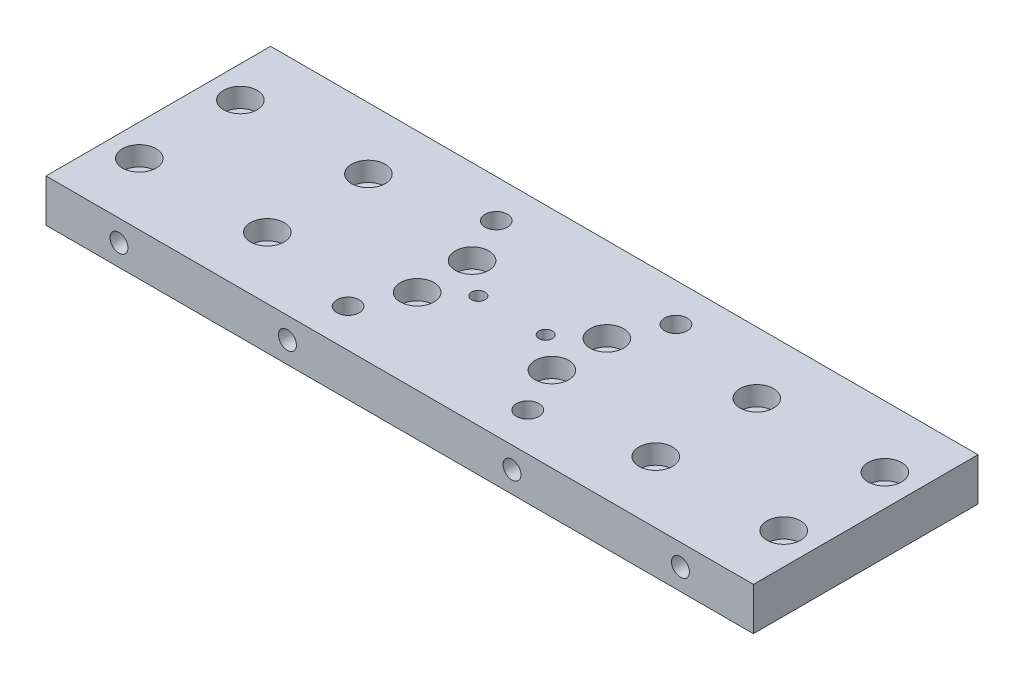
from build123d import *

# Parameters (mm, degrees)
ESBO_O1_W                                            = 315
ESBO_O1_H                                            = 100
RESSALTO_EXTRUS_O1_DEPTH                             = 19.02
ESBO_O2_R                                            = 2
CORTE_EXTRUS_O1_DEPTH                                = 25
ESBO_O4_R                                            = 5
CORTE_EXTRUS_O3_DEPTH                                = 20.02
ESBO_O5_R                                            = 3.3
CORTE_EXTRUS_O4_DEPTH                                = 90
REBAIXO_PARA_PARAFUSO_ALLEN_SEXTAVADO_DE_D           = 9
REBAIXO_PARA_PARAFUSO_ALLEN_SEXTAVADO_DE_DEPTH       = 19.02
REBAIXO_PARA_PARAFUSO_ALLEN_SEXTAVADO_DE_CBORE_D     = 15
REBAIXO_PARA_PARAFUSO_ALLEN_SEXTAVADO_DE_CBORE_DEPTH = 8.6
ESBO_O13_R                                           = 4
CORTE_EXTRUS_O8_DEPTH                                = 20
ESBO_O14_R                                           = 4
CORTE_EXTRUS_O9_DEPTH                                = 20
ESBO_O15_R                                           = 4
ESBO_O15_R_2                                         = 3
CORTE_EXTRUS_O10_DEPTH                               = 20.02
ESBO_O16_R                                           = 3.3
RESSALTO_EXTRUS_O2_DEPTH                             = 19.02
REBAIXO_PARA_PARAFUSO_ALLEN_SEXTAVAD_2_D             = 9
REBAIXO_PARA_PARAFUSO_ALLEN_SEXTAVAD_2_CBORE_D       = 15
REBAIXO_PARA_PARAFUSO_ALLEN_SEXTAVAD_2_CBORE_DEPTH   = 8.6


with BuildPart() as part:
    # Esboço1 → Ressalto-extrusão1 (new body)
    with BuildSketch(Plane(origin=(0, 0, 0), x_dir=(1, 0, 0), z_dir=(0, 1, 0))):
        Rectangle(ESBO_O1_W, ESBO_O1_H)
    extrude(amount=RESSALTO_EXTRUS_O1_DEPTH)

    # Esboço2 → Corte-extrusão1 (cut)
    with BuildSketch(Plane(origin=(0, 19.02, 0), x_dir=(1, 0, 0), z_dir=(0, 1, 0))):
        with Locations((143.5, 22.5)):
            Circle(ESBO_O2_R)
        with Locations((86.5, 22.5)):
            Circle(ESBO_O2_R)
        with Locations((86.5, -22.5)):
            Circle(ESBO_O2_R)
        with Locations((143.5, -22.5)):
            Circle(ESBO_O2_R)
        with Locations((-86.5, -22.45)):
            Circle(ESBO_O2_R)
        with Locations((-143.5, -22.45)):
            Circle(ESBO_O2_R)
        with Locations((-143.5, 22.55)):
            Circle(ESBO_O2_R)
        with Locations((-86.5, 22.55)):
            Circle(ESBO_O2_R)
    extrude(amount=-CORTE_EXTRUS_O1_DEPTH, mode=Mode.SUBTRACT)

    # Esboço4 → Corte-extrusão3 (cut, through all)
    with BuildSketch(Plane(origin=(0, 19.02, 0), x_dir=(1, 0, 0), z_dir=(0, 1, 0))):
        with Locations((-40, -32.999878702)):
            Circle(ESBO_O4_R)
        with Locations((-40, 33)):
            Circle(ESBO_O4_R)
        with Locations((40, 33)):
            Circle(ESBO_O4_R)
        with Locations((40, -33)):
            Circle(ESBO_O4_R)
    extrude(amount=-CORTE_EXTRUS_O3_DEPTH, mode=Mode.SUBTRACT)

    # Esboço5 → Corte-extrusão4 (cut)
    with BuildSketch(Plane(origin=(0, 19.02, 0), x_dir=(1, 0, 0), z_dir=(0, 1, 0))):
        Circle(ESBO_O5_R)
    extrude(amount=-CORTE_EXTRUS_O4_DEPTH, mode=Mode.SUBTRACT)

    # Rebaixo para parafuso Allen sextavado de
    with Locations(Plane(origin=(-143.5, 19.02, -22.55), x_dir=(0, 0, 1), z_dir=(0, 1, 0))):
        with Locations((0, 0), (45, 57), (0, 57), (45, 0), (0.05, 230), (0.05, 287), (45.05, 230), (45.05, 287)):
            CounterBoreHole(REBAIXO_PARA_PARAFUSO_ALLEN_SEXTAVADO_DE_D / 2, REBAIXO_PARA_PARAFUSO_ALLEN_SEXTAVADO_DE_CBORE_D / 2, REBAIXO_PARA_PARAFUSO_ALLEN_SEXTAVADO_DE_CBORE_DEPTH, depth=REBAIXO_PARA_PARAFUSO_ALLEN_SEXTAVADO_DE_DEPTH)

    # Esboço13 → Corte-extrusão8 (cut)
    with BuildSketch(Plane.XY.offset(50)):
        with Locations((-125, 9.51)):
            Circle(ESBO_O13_R)
        with Locations((-50, 9.51)):
            Circle(ESBO_O13_R)
        with Locations((50, 9.51)):
            Circle(ESBO_O13_R)
        with Locations((125, 9.51)):
            Circle(ESBO_O13_R)
    extrude(amount=-CORTE_EXTRUS_O8_DEPTH, mode=Mode.SUBTRACT)

    # Esboço14 → Corte-extrusão9 (cut)
    with BuildSketch(Plane(origin=(0, 0, -50), x_dir=(-1, 0, 0), z_dir=(0, 0, -1))):
        with Locations((-125, 9.51)):
            Circle(ESBO_O14_R)
        with Locations((-50, 9.51)):
            Circle(ESBO_O14_R)
        with Locations((50, 9.51)):
            Circle(ESBO_O14_R)
        with Locations((125, 9.51)):
            Circle(ESBO_O14_R)
    extrude(amount=-CORTE_EXTRUS_O9_DEPTH, mode=Mode.SUBTRACT)

    # Esboço15 → Corte-extrusão10 (cut, through all)
    with BuildSketch(Plane(origin=(0, 19.02, 0), x_dir=(1, 0, 0), z_dir=(0, 1, 0))):
        with Locations((30, 12.225)):
            Circle(ESBO_O15_R)
        with Locations((30, -12.225)):
            Circle(ESBO_O15_R)
        with Locations((-30, 12.225)):
            Circle(ESBO_O15_R)
        with Locations((-30, -12.225)):
            Circle(ESBO_O15_R)
        with Locations((-15, 0)):
            Circle(ESBO_O15_R_2)
        with Locations((15, 0)):
            Circle(ESBO_O15_R_2)
    extrude(amount=-CORTE_EXTRUS_O10_DEPTH, mode=Mode.SUBTRACT)

    # Esboço16 → Ressalto-extrusão2 (add)
    with BuildSketch(Plane(origin=(0, 19.02, 0), x_dir=(1, 0, 0), z_dir=(0, 1, 0))):
        Circle(ESBO_O16_R)
    extrude(amount=-RESSALTO_EXTRUS_O2_DEPTH)

    # Rebaixo para parafuso Allen sextavad 2 (through all)
    with Locations(Plane(origin=(-30, 19.02, -12.225), x_dir=(0, 0, 1), z_dir=(0, 1, 0))):
        with Locations((0, 0), (0, 60), (24.45, 60), (24.45, 0)):
            CounterBoreHole(REBAIXO_PARA_PARAFUSO_ALLEN_SEXTAVAD_2_D / 2, REBAIXO_PARA_PARAFUSO_ALLEN_SEXTAVAD_2_CBORE_D / 2, REBAIXO_PARA_PARAFUSO_ALLEN_SEXTAVAD_2_CBORE_DEPTH)


solid = part.part
